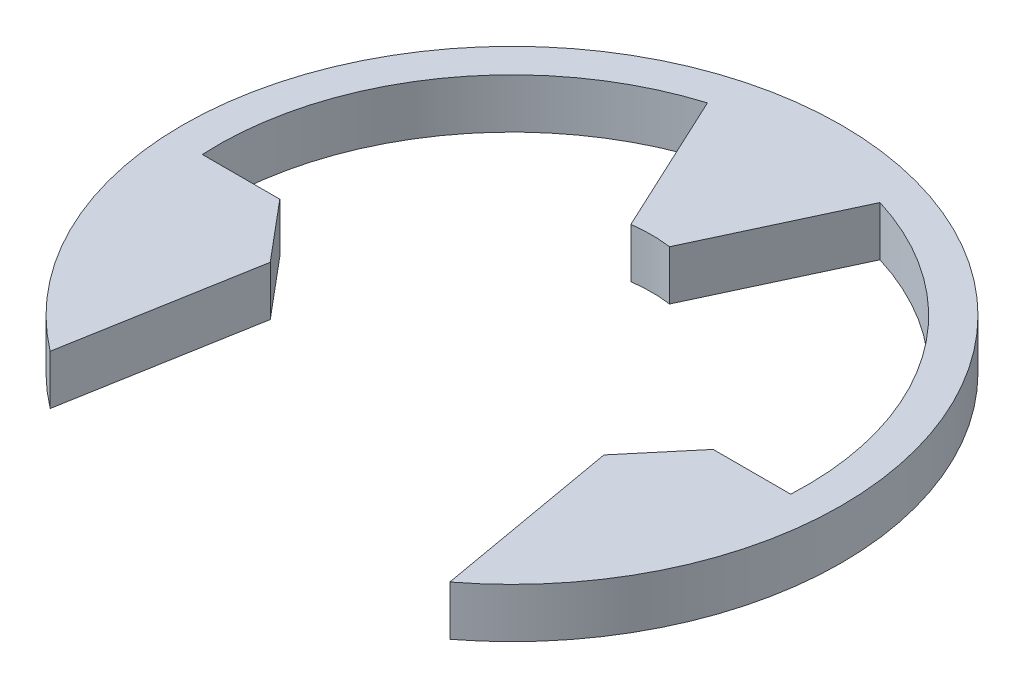
from build123d import *

# Parameters (mm, degrees)
BOSS_EXTRUDE1_DEPTH = 0.64


with BuildPart() as part:
    # Sketch1 → Boss-Extrude1 (new body)
    with BuildSketch(Plane(origin=(0, 0, 0), x_dir=(1, 0, 0), z_dir=(0, 1, 0))):
        with BuildLine():
            Line((-1.112579474, 3.633478624), (-0.249511241, 1.782622826))
            ThreePointArc((-0.249511241, 1.782622826), (0, 1.8), (0.249511241, 1.782622826))
            Line((0.249511241, 1.782622826), (1.112579474, 3.633478624))
            ThreePointArc((1.112579474, 3.633478624), (2.774739275, 2.596309295), (3.699307386, 0.868979208))
            ThreePointArc((3.699307386, 0.868979208), (3.784949165, 0.337875445), (3.794733192, -0.2))
            Line((3.794733192, -0.2), (2.794733192, -0.2))
            Line((2.794733192, -0.2), (2.151945583, -0.966044443))
            Line((2.151945583, -0.966044443), (2.57594692, -3.370675522))
            Line((2.57594692, -3.370675522), (2.577455967, -3.37923375))
            ThreePointArc((2.577455967, -3.37923375), (0, 4.25), (-2.577455967, -3.37923375))
            Line((-2.577455967, -3.37923375), (-2.576768139, -3.375332886))
            Line((-2.576768139, -3.375332886), (-2.151945583, -0.966044443))
            Line((-2.151945583, -0.966044443), (-2.794733192, -0.2))
            Line((-2.794733192, -0.2), (-3.794733192, -0.2))
            ThreePointArc((-3.794733192, -0.2), (-3.784949165, 0.337875445), (-3.699307386, 0.868979208))
            ThreePointArc((-3.699307386, 0.868979208), (-2.774739275, 2.596309295), (-1.112579474, 3.633478624))
        make_face()
    extrude(amount=BOSS_EXTRUDE1_DEPTH)


solid = part.part
